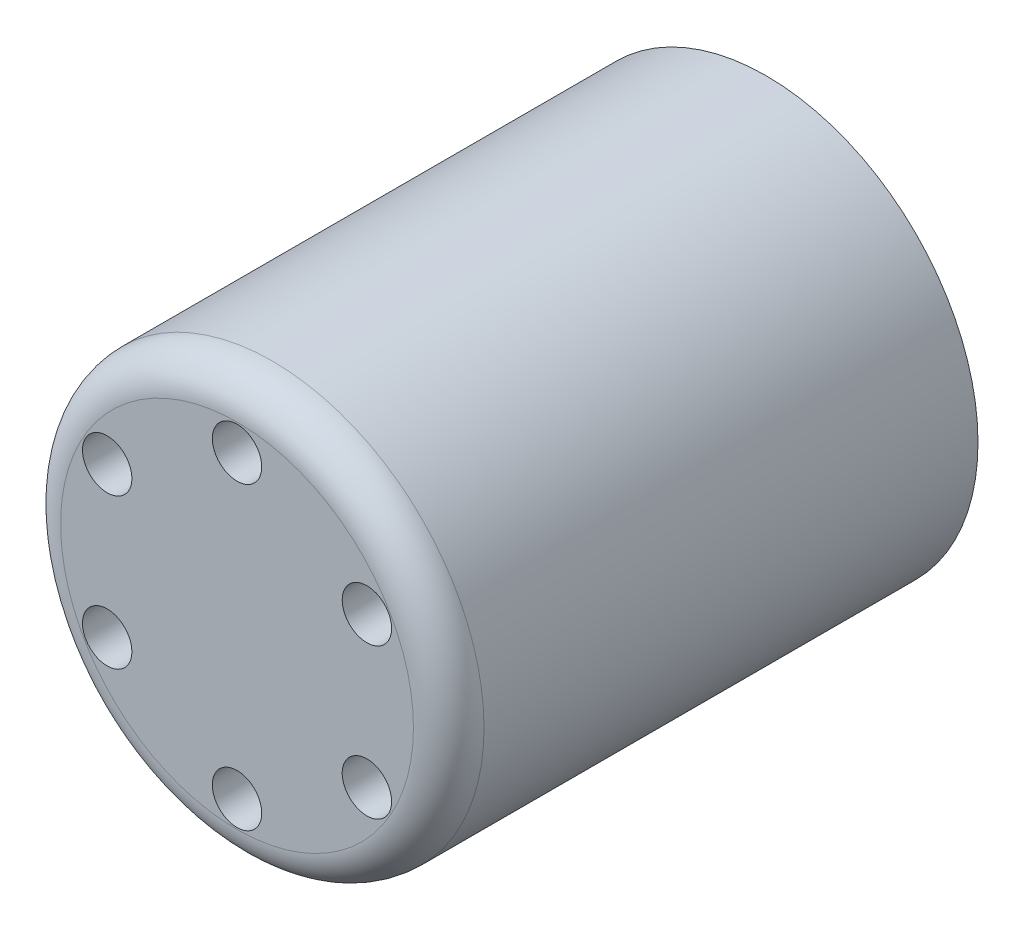
from build123d import *

# Parameters (mm, degrees)
SKETCH1_R           = 6
BOSS_EXTRUDE1_DEPTH = 15
SKETCH2_R           = 0.7
CUT_EXTRUDE1_DEPTH  = 3
CIRPATTERN1_COUNT   = 6
FILLET1_R           = 1


with BuildPart() as part:
    # Sketch1 → Boss-Extrude1 (new body)
    with BuildSketch(Plane.XY):
        Circle(SKETCH1_R)
    extrude(amount=BOSS_EXTRUDE1_DEPTH)

    # Sketch2 → Cut-Extrude1 (cut)
    with BuildSketch(Plane.XY.offset(15)):
        with Locations((0, 4.25)):
            Circle(SKETCH2_R)
    cut_extrude1 = extrude(amount=-CUT_EXTRUDE1_DEPTH, mode=Mode.SUBTRACT)

    # CirPattern1: Cut-Extrude1 ×6 about axis
    cirpattern1_axis = Axis((0, 0, 0), (0, 0, 1))
    for i in range(1, CIRPATTERN1_COUNT):
        add(cut_extrude1.rotate(cirpattern1_axis, i * 360 / CIRPATTERN1_COUNT), mode=Mode.SUBTRACT)

    # Fillet1
    fillet1_edges = [part.edges().sort_by_distance(p)[0] for p in [
        (-6, 0, 15),
    ]]
    fillet(fillet1_edges, radius=FILLET1_R)


solid = part.part
